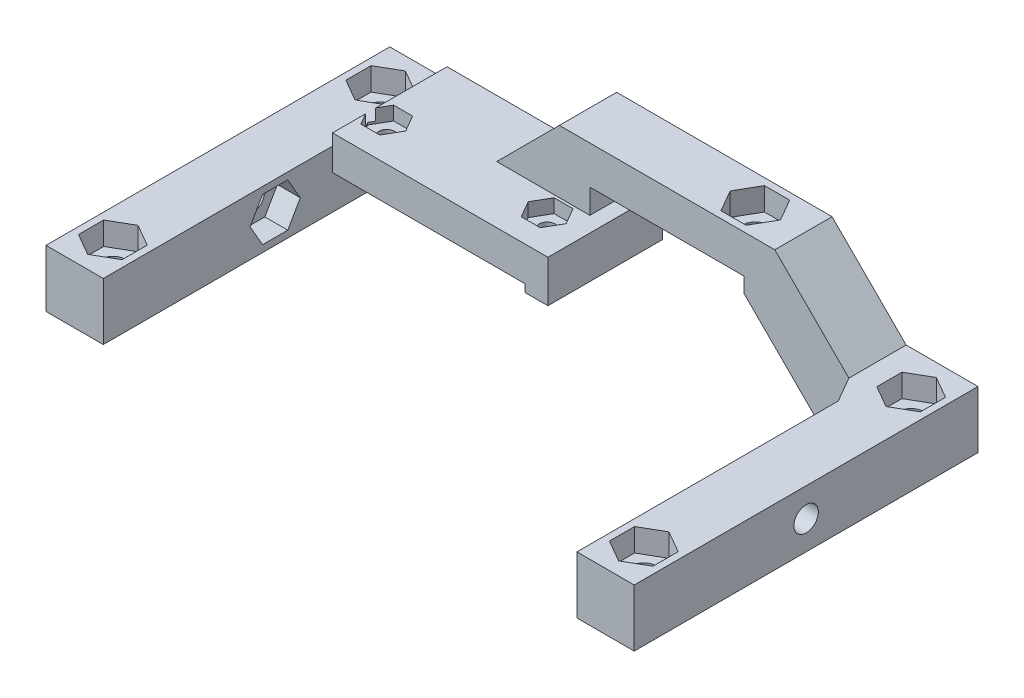
from build123d import *

# Parameters (mm, degrees)
SALIENTE_EXTRUIR1_DEPTH = 7.5
SALIENTE_EXTRUIR2_DEPTH = 7.5
CROQUIS3_W              = 7.5
CROQUIS3_H              = 7.5
SALIENTE_EXTRUIR3_DEPTH = 30
SALIENTE_EXTRUIR4_DEPTH = 7.5
CROQUIS5_W              = 7.5
CROQUIS5_H              = 7.5
SALIENTE_EXTRUIR5_DEPTH = 37.5
CORTAR_EXTRUIR1_REACH   = 19.2
CROQUIS7_R              = 1.6
CORTAR_EXTRUIR2_DEPTH   = 4.5
CORTAR_EXTRUIR3_REACH   = 7
CROQUIS9_R              = 1.6
CORTAR_EXTRUIR4_DEPTH   = 3
CORTAR_EXTRUIR5_REACH   = 14.7
CROQUIS11_R             = 1.05
CORTAR_EXTRUIR6_DEPTH   = 1.8
CORTAR_EXTRUIR7_REACH   = 79
CROQUIS13_R             = 1.6
CORTAR_EXTRUIR8_DEPTH   = 3
CORTAR_EXTRUIR9_REACH   = 79
CROQUIS16_R             = 1.6
CORTAR_EXTRUIR10_DEPTH  = 3


with BuildPart() as part:
    # Croquis1 → Saliente-Extruir1 (new body)
    with BuildSketch(Plane.XY):
        Polygon((0, 0), (7.5, 0), (7.5, 4.5), (32.7, 4.5), (32.7, 3.5), (35.7, 3.5), (35.7, 9), (33.7, 9), (33.7, 12.2), (53.9, 12.2), (53.9, 10.2), (64.1, 0), (77, 0), (77, 7.5), (67.6, 7.5), (57.9, 17.2), (29.7, 17.2), (21.5, 9), (7.5, 9), (7.5, 7.5), (0, 7.5), align=None)
    extrude(amount=SALIENTE_EXTRUIR1_DEPTH)

    # Croquis2 → Saliente-Extruir2 (add)
    with BuildSketch(Plane.XY.offset(7.5)):
        Polygon((0, 7.5), (7.5, 7.5), (7.5, 9), (35.7, 9), (35.7, 7.5), (35.7, 3.5), (32.7, 3.5), (32.7, 4.5), (7.5, 4.5), (7.5, 0), (0, 0), align=None)
    extrude(amount=SALIENTE_EXTRUIR2_DEPTH)

    # Croquis3 → Saliente-Extruir3 (add)
    with BuildSketch(Plane.XY.offset(15)):
        with Locations((3.75, 3.75)):
            Rectangle(CROQUIS3_W, CROQUIS3_H)
    extrude(amount=SALIENTE_EXTRUIR3_DEPTH)

    # Croquis4 → Saliente-Extruir4 (add)
    with BuildSketch(Plane(origin=(0, 7.5, 0), x_dir=(1, 0, 0), z_dir=(0, 1, 0))):
        Polygon((67.6, -7.5), (69.5, -10.790896534), (69.5, -7.5), align=None)
    extrude(amount=-SALIENTE_EXTRUIR4_DEPTH)

    # Croquis5 → Saliente-Extruir5 (add)
    with BuildSketch(Plane.XY.offset(7.5)):
        with Locations((73.25, 3.75)):
            Rectangle(CROQUIS5_W, CROQUIS5_H)
    extrude(amount=SALIENTE_EXTRUIR5_DEPTH)

    # Croquis7 → Cortar-Extruir1 (cut, up to next)
    with BuildSketch(Plane.XZ, mode=Mode.PRIVATE) as cortar_extruir1_sk1:
        with Locations((73.25, 5)):
            Circle(CROQUIS7_R)
    cortar_extruir1_tool1 = extrude(cortar_extruir1_sk1.sketch, amount=-CORTAR_EXTRUIR1_REACH, mode=Mode.PRIVATE) & part.part
    add(cortar_extruir1_tool1.solids().sort_by_distance((73.25, 0, 5))[0], mode=Mode.SUBTRACT)
    # Croquis7 → Cortar-Extruir1 (cut, up to next)
    with BuildSketch(Plane.XZ, mode=Mode.PRIVATE) as cortar_extruir1_sk2:
        with Locations((73.25, 40)):
            Circle(CROQUIS7_R)
    cortar_extruir1_tool2 = extrude(cortar_extruir1_sk2.sketch, amount=-CORTAR_EXTRUIR1_REACH, mode=Mode.PRIVATE) & part.part
    add(cortar_extruir1_tool2.solids().sort_by_distance((73.25, 0, 40))[0], mode=Mode.SUBTRACT)
    # Croquis7 → Cortar-Extruir1 (cut, up to next)
    with BuildSketch(Plane.XZ, mode=Mode.PRIVATE) as cortar_extruir1_sk3:
        with Locations((3.75, 5)):
            Circle(CROQUIS7_R)
    cortar_extruir1_tool3 = extrude(cortar_extruir1_sk3.sketch, amount=-CORTAR_EXTRUIR1_REACH, mode=Mode.PRIVATE) & part.part
    add(cortar_extruir1_tool3.solids().sort_by_distance((3.75, 0, 5))[0], mode=Mode.SUBTRACT)
    # Croquis7 → Cortar-Extruir1 (cut, up to next)
    with BuildSketch(Plane.XZ, mode=Mode.PRIVATE) as cortar_extruir1_sk4:
        with Locations((3.75, 40)):
            Circle(CROQUIS7_R)
    cortar_extruir1_tool4 = extrude(cortar_extruir1_sk4.sketch, amount=-CORTAR_EXTRUIR1_REACH, mode=Mode.PRIVATE) & part.part
    add(cortar_extruir1_tool4.solids().sort_by_distance((3.75, 0, 40))[0], mode=Mode.SUBTRACT)

    # Croquis8 → Cortar-Extruir2 (cut)
    with BuildSketch(Plane(origin=(0, 9, 0), x_dir=(1, 0, 0), z_dir=(0, 1, 0))):
        Polygon((0.9, -3.354551733), (0.9, -6.645448267), (3.75, -8.290896534), (6.6, -6.645448267), (6.6, -3.354551733), (3.75, -1.709103466), align=None)
        Polygon((0.9, -38.354551733), (0.9, -41.645448267), (3.75, -43.290896534), (6.6, -41.645448267), (6.6, -38.354551733), (3.75, -36.709103466), align=None)
        Polygon((70.4, -38.354551733), (70.4, -41.645448267), (73.25, -43.290896534), (76.1, -41.645448267), (76.1, -38.354551733), (73.25, -36.709103466), align=None)
        Polygon((70.4, -3.354551733), (70.4, -6.645448267), (73.25, -8.290896534), (76.1, -6.645448267), (76.1, -3.354551733), (73.25, -1.709103466), align=None)
    extrude(amount=-CORTAR_EXTRUIR2_DEPTH, mode=Mode.SUBTRACT)

    # Croquis9 → Cortar-Extruir3 (cut, up to next)
    with BuildSketch(Plane.XZ.offset(-12.2), mode=Mode.PRIVATE) as cortar_extruir3_sk1:
        with Locations((51.6, 3.75)):
            Circle(CROQUIS9_R)
    cortar_extruir3_tool1 = extrude(cortar_extruir3_sk1.sketch, amount=-CORTAR_EXTRUIR3_REACH, mode=Mode.PRIVATE) & part.part
    add(cortar_extruir3_tool1.solids().sort_by_distance((51.6, 12.2, 3.75))[0], mode=Mode.SUBTRACT)

    # Croquis10 → Cortar-Extruir4 (cut)
    with BuildSketch(Plane(origin=(0, 17.2, 0), x_dir=(1, 0, 0), z_dir=(0, 1, 0))):
        Polygon((49.954551733, -0.9), (48.309103466, -3.75), (49.954551733, -6.6), (53.245448267, -6.6), (54.890896534, -3.75), (53.245448267, -0.9), align=None)
    extrude(amount=-CORTAR_EXTRUIR4_DEPTH, mode=Mode.SUBTRACT)

    # Croquis11 → Cortar-Extruir5 (cut, up to next)
    with BuildSketch(Plane.XZ.offset(-4.5), mode=Mode.PRIVATE) as cortar_extruir5_sk1:
        with Locations((30.6, 10)):
            Circle(CROQUIS11_R)
    cortar_extruir5_tool1 = extrude(cortar_extruir5_sk1.sketch, amount=-CORTAR_EXTRUIR5_REACH, mode=Mode.PRIVATE) & part.part
    add(cortar_extruir5_tool1.solids().sort_by_distance((30.6, 4.5, 10))[0], mode=Mode.SUBTRACT)
    # Croquis11 → Cortar-Extruir5 (cut, up to next)
    with BuildSketch(Plane.XZ.offset(-4.5), mode=Mode.PRIVATE) as cortar_extruir5_sk2:
        with Locations((9.6, 10)):
            Circle(CROQUIS11_R)
    cortar_extruir5_tool2 = extrude(cortar_extruir5_sk2.sketch, amount=-CORTAR_EXTRUIR5_REACH, mode=Mode.PRIVATE) & part.part
    add(cortar_extruir5_tool2.solids().sort_by_distance((9.6, 4.5, 10))[0], mode=Mode.SUBTRACT)

    # Croquis12 → Cortar-Extruir6 (cut)
    with BuildSketch(Plane(origin=(0, 9, 0), x_dir=(1, 0, 0), z_dir=(0, 1, 0))):
        Polygon((8.358696921, -12.15), (10.841303079, -12.15), (12.082606158, -10), (10.841303079, -7.85), (8.358696921, -7.85), (7.117393842, -10), align=None)
        Polygon((28.117393842, -10), (29.358696921, -12.15), (31.841303079, -12.15), (33.082606158, -10), (31.841303079, -7.85), (29.358696921, -7.85), align=None)
    extrude(amount=-CORTAR_EXTRUIR6_DEPTH, mode=Mode.SUBTRACT)

    # Croquis13 → Cortar-Extruir7 (cut, up to next)
    with BuildSketch(Plane.ZY, mode=Mode.PRIVATE) as cortar_extruir7_sk1:
        with Locations((22.5, 3.75)):
            Circle(CROQUIS13_R)
    cortar_extruir7_tool1 = extrude(cortar_extruir7_sk1.sketch, amount=-CORTAR_EXTRUIR7_REACH, mode=Mode.PRIVATE) & part.part
    add(cortar_extruir7_tool1.solids().sort_by_distance((0, 3.75, 22.5))[0], mode=Mode.SUBTRACT)

    # Croquis15 → Cortar-Extruir8 (cut)
    with BuildSketch(Plane(origin=(7.5, 0, 0), x_dir=(0, 0, -1), z_dir=(1, 0, 0))):
        Polygon((-24.145448267, 0.9), (-20.854551733, 0.9), (-19.209103466, 3.75), (-20.854551733, 6.6), (-24.145448267, 6.6), (-25.790896534, 3.75), align=None)
    extrude(amount=-CORTAR_EXTRUIR8_DEPTH, mode=Mode.SUBTRACT)

    # Croquis16 → Cortar-Extruir9 (cut, up to next)
    with BuildSketch(Plane(origin=(77, 0, 0), x_dir=(0, 0, -1), z_dir=(1, 0, 0)), mode=Mode.PRIVATE) as cortar_extruir9_sk1:
        with Locations((-22.5, 3.75)):
            Circle(CROQUIS16_R)
    cortar_extruir9_tool1 = extrude(cortar_extruir9_sk1.sketch, amount=-CORTAR_EXTRUIR9_REACH, mode=Mode.PRIVATE) & part.part
    add(cortar_extruir9_tool1.solids().sort_by_distance((77, 3.75, 22.5))[0], mode=Mode.SUBTRACT)

    # Croquis17 → Cortar-Extruir10 (cut)
    with BuildSketch(Plane.ZY.offset(-69.5)):
        Polygon((20.854551733, 0.9), (24.145448267, 0.9), (25.790896534, 3.75), (24.145448267, 6.6), (20.854551733, 6.6), (19.209103466, 3.75), align=None)
    extrude(amount=-CORTAR_EXTRUIR10_DEPTH, mode=Mode.SUBTRACT)


solid = part.part
